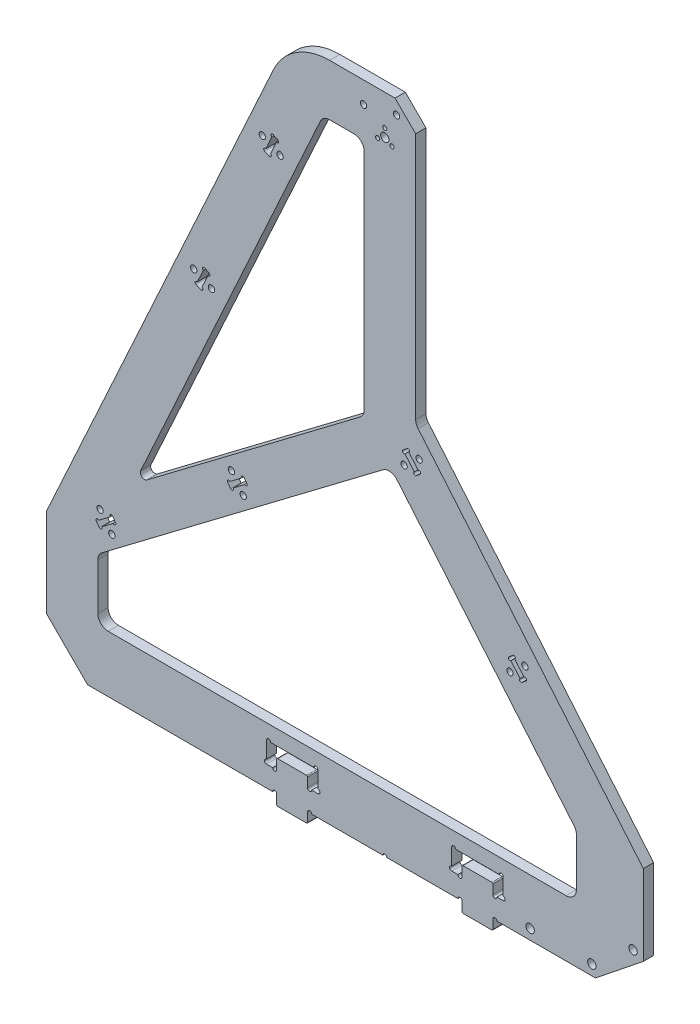
from build123d import *

# Parameters (mm, degrees)
SKETCH_1_R          = 2
SKETCH_1_R_2        = 1
SKETCH_1_R_3        = 2.05
EXTRUDE_1_DEPTH     = 2.5
EXTRUDE_2_DEPTH     = 5
CHAMFER_1_SIZE      = 10
FILLET_1_R          = 5
FILLET_2_R          = 2
CHAMFER_2_SIZE      = 20
FILLET_3_R          = 30
CUT_EXTRUDE_1_DEPTH = 6
SKETCH_4_R          = 1.55
CUT_EXTRUDE_2_DEPTH = 6
SKETCH_5_R          = 0.75
CUT_EXTRUDE_3_DEPTH = 6
SKETCH_6_R          = 1.55
CUT_EXTRUDE_4_DEPTH = 6
SKETCH_7_R          = 1
CUT_EXTRUDE_5_DEPTH = 6
SKETCH_8_W          = 15
SKETCH_8_H          = 5
EXTRUDE_3_DEPTH     = 5
CUT_EXTRUDE_7_DEPTH = 6
SKETCH_9_R          = 1
CUT_EXTRUDE_6_DEPTH = 6
FILLET_4_R          = 0.5


with BuildPart() as part:
    # 草图1 → 凸台-拉伸1 (new body, symmetric)
    with BuildSketch(Plane.XY):
        Polygon((-46.051103509, 19), (15, 19), (15, -113.030948747), (125.6, -244.838896088), (125.6, -302.5), (-164.4, -302.5), (-164.4, -239.550148641), align=None)
        Circle(SKETCH_1_R, mode=Mode.SUBTRACT)
        with Locations((0, 4)):
            Circle(SKETCH_1_R_2, mode=Mode.SUBTRACT)
        with Locations((3.464101615, -2)):
            Circle(SKETCH_1_R_2, mode=Mode.SUBTRACT)
        with Locations((-3.464101615, -2)):
            Circle(SKETCH_1_R_2, mode=Mode.SUBTRACT)
        with Locations((70.6, -297.5)):
            Circle(SKETCH_1_R_3, mode=Mode.SUBTRACT)
        with Locations((100.6, -297.5)):
            Circle(SKETCH_1_R_3, mode=Mode.SUBTRACT)
        with Locations((120.6, -281.5)):
            Circle(SKETCH_1_R_3, mode=Mode.SUBTRACT)
        Polygon((93.1, -245), (93.1, -275), (-139.4, -275), (-139.4, -245), (-30, -6), (-10, -6), (-10, -122.130204604), align=None, mode=Mode.SUBTRACT)
    extrude(amount=EXTRUDE_1_DEPTH, both=True)

    # 草图2 → 凸台-拉伸2 (add)
    with BuildSketch(Plane.XY.offset(2.5)):
        Polygon((-139.4, -245), (2.872444028, -137.470986019), (-10, -122.130204604), (-121.854574134, -206.669499251), align=None)
    extrude(amount=-EXTRUDE_2_DEPTH)

    # 倒角1
    chamfer_1_edges = [part.edges().sort_by_distance(p)[0] for p in [
        (15, 19, 0),
    ]]
    chamfer(chamfer_1_edges, length=CHAMFER_1_SIZE)

    # 圆角1
    fillet_1_edges = [part.edges().sort_by_distance(p)[0] for p in [
        (15, -113.030948747, 0),
        (93.1, -245, 0),
        (-10, -122.130204604, 0),
        (-10, -6, 0),
        (-30, -6, 0),
        (-139.4, -245, 0),
        (-139.4, -275, 0),
        (93.1, -275, 0),
        (2.872444028, -137.470986019, 0),
    ]]
    fillet(fillet_1_edges, radius=FILLET_1_R)

    # 圆角2
    fillet_2_edges = [part.edges().sort_by_distance(p)[0] for p in [
        (-121.854574134, -206.669499251, 0),
    ]]
    fillet(fillet_2_edges, radius=FILLET_2_R)

    # 倒角2
    chamfer_2_edges = [part.edges().sort_by_distance(p)[0] for p in [
        (-164.4, -302.5, 0),
    ]]
    chamfer(chamfer_2_edges, length=CHAMFER_2_SIZE)

    # 圆角3
    fillet_3_edges = [part.edges().sort_by_distance(p)[0] for p in [
        (-46.051103509, 19, 0),
    ]]
    fillet(fillet_3_edges, radius=FILLET_3_R)

    # 草图3 → 切除-拉伸1 (cut, through all)
    with BuildSketch(Plane.XY.offset(2.5)):
        Polygon((125.6, -283.903124237), (102.353905297, -302.5), (125.6, -302.5), align=None)
    extrude(amount=-CUT_EXTRUDE_1_DEPTH, mode=Mode.SUBTRACT)

    # 草图4 → 切除-拉伸2 (cut, through all)
    with BuildSketch(Plane.XY.offset(2.5)):
        with Locations((-84.165975689, -105.712906131)):
            Circle(SKETCH_4_R)
        with Locations((-92.804029823, -101.758918171)):
            Circle(SKETCH_4_R)
        with Locations((-50.86923498, -32.971397635)):
            Circle(SKETCH_4_R)
        with Locations((-59.507289114, -29.017409676)):
            Circle(SKETCH_4_R)
        with Locations((-74.508632231, -177.466406471)):
            Circle(SKETCH_4_R)
        with Locations((-68.780555523, -185.045267679)):
            Circle(SKETCH_4_R)
        with Locations((-132.60254465, -233.281703119)):
            Circle(SKETCH_4_R)
        with Locations((-138.330621358, -225.70284191)):
            Circle(SKETCH_4_R)
        with Locations((68.083818222, -188.35063948)):
            Circle(SKETCH_4_R)
        with Locations((60.806396012, -194.457121772)):
            Circle(SKETCH_4_R)
        with Locations((16.660809447, -127.06708403)):
            Circle(SKETCH_4_R)
        with Locations((9.383387237, -133.173566322)):
            Circle(SKETCH_4_R)
        Polygon((10.781785538, -125.50576956), (8.86667443, -127.112738584), (15.262411147, -134.734880793), (17.177522254, -133.127911769), align=None)
        Polygon((60.289683205, -188.396294033), (62.204794313, -186.789325009), (68.600531029, -194.411467218), (66.685419921, -196.018436242), align=None)
        Polygon((-138.681818649, -233.489194423), (-130.743958751, -227.489787765), (-132.251347359, -225.495350605), (-140.189207257, -231.494757263), align=None)
        Polygon((-76.36721813, -183.258321824), (-68.429358232, -177.258915166), (-66.921969624, -179.253352326), (-74.859829522, -185.252758984), align=None)
        Polygon((-54.254207055, -25.950529523), (-51.981034914, -26.99105267), (-56.12231704, -36.038277789), (-58.39548918, -34.997754642), align=None)
        Polygon((-85.277775623, -99.732561165), (-87.550947763, -98.692038018), (-91.692229889, -107.739263137), (-89.419057749, -108.779786284), align=None)
    extrude(amount=-CUT_EXTRUDE_2_DEPTH, mode=Mode.SUBTRACT)

    # 草图5 → 切除-拉伸3 (cut, through all)
    with BuildSketch(Plane.XY.offset(2.5)):
        with Locations((-85.589932567, -100.414512807)):
            Circle(SKETCH_5_R)
        with Locations((-87.863104708, -99.37398966)):
            Circle(SKETCH_5_R)
        with Locations((-91.380072945, -107.057311495)):
            Circle(SKETCH_5_R)
        with Locations((-89.106900804, -108.097834642)):
            Circle(SKETCH_5_R)
        with Locations((-58.083332236, -34.315803)):
            Circle(SKETCH_5_R)
        with Locations((-55.810160096, -35.356326147)):
            Circle(SKETCH_5_R)
        with Locations((-54.566363999, -26.632481165)):
            Circle(SKETCH_5_R)
        with Locations((-52.293191858, -27.673004312)):
            Circle(SKETCH_5_R)
        with Locations((-139.590876108, -231.042540681)):
            Circle(SKETCH_5_R)
        with Locations((-138.083487501, -233.036977841)):
            Circle(SKETCH_5_R)
        with Locations((-132.849678507, -225.947567187)):
            Circle(SKETCH_5_R)
        with Locations((-131.342289899, -227.942004348)):
            Circle(SKETCH_5_R)
        with Locations((-74.261498374, -184.800542402)):
            Circle(SKETCH_5_R)
        with Locations((-75.768886981, -182.806105242)):
            Circle(SKETCH_5_R)
        with Locations((-69.02768938, -177.711131748)):
            Circle(SKETCH_5_R)
        with Locations((-67.520300772, -179.705568908)):
            Circle(SKETCH_5_R)
        with Locations((9.348765137, -127.687271916)):
            Circle(SKETCH_5_R)
        with Locations((11.263876245, -126.080302892)):
            Circle(SKETCH_5_R)
        with Locations((14.780320439, -134.160347461)):
            Circle(SKETCH_5_R)
        with Locations((16.695431547, -132.553378436)):
            Circle(SKETCH_5_R)
        with Locations((60.771773912, -188.970827366)):
            Circle(SKETCH_5_R)
        with Locations((62.68688502, -187.363858341)):
            Circle(SKETCH_5_R)
        with Locations((66.203329214, -195.44390291)):
            Circle(SKETCH_5_R)
        with Locations((68.118440322, -193.836933886)):
            Circle(SKETCH_5_R)
    extrude(amount=-CUT_EXTRUDE_3_DEPTH, mode=Mode.SUBTRACT)

    # 草图6 → 切除-拉伸4 (cut, through all)
    with BuildSketch(Plane.XY.offset(2.5)):
        with Locations((-10.341599982, 8.677632731)):
            Circle(SKETCH_6_R)
        with Locations((5.705346533, 12.235155125)):
            Circle(SKETCH_6_R)
    extrude(amount=-CUT_EXTRUDE_4_DEPTH, mode=Mode.SUBTRACT)

    # 草图7 → 切除-拉伸5 (cut, through all)
    with BuildSketch(Plane.XY.offset(2.5)):
        with Locations((0, -302.5)):
            Circle(SKETCH_7_R)
    extrude(amount=-CUT_EXTRUDE_5_DEPTH, mode=Mode.SUBTRACT)

    # 草图8 → 凸台-拉伸3 (add)
    with BuildSketch(Plane.XY.offset(2.5)):
        with Locations((-45, -305)):
            Rectangle(SKETCH_8_W, SKETCH_8_H)
        with Locations((45, -305)):
            Rectangle(SKETCH_8_W, SKETCH_8_H)
    extrude(amount=-EXTRUDE_3_DEPTH)

    # 草图10 → 切除-拉伸7 (cut, through all)
    with BuildSketch(Plane.XY.offset(2.5)):
        Polygon((-57.5, -282.3), (-57.5, -292.4), (-52.5, -292.4), (-52.5, -287.4), (-37.5, -287.4), (-37.5, -292.4), (-32.5, -292.4), (-32.5, -282.3), align=None)
        Polygon((32.5, -282.3), (57.5, -282.3), (57.5, -292.4), (52.5, -292.4), (52.5, -287.4), (37.5, -287.4), (37.5, -292.4), (32.5, -292.4), align=None)
    extrude(amount=-CUT_EXTRUDE_7_DEPTH, mode=Mode.SUBTRACT)

    # 草图9 → 切除-拉伸6 (cut, through all)
    with BuildSketch(Plane.XY.offset(2.5)):
        with Locations((-53.5, -302.5)):
            Circle(SKETCH_9_R)
        with Locations((-36.5, -302.5)):
            Circle(SKETCH_9_R)
        with Locations((36.5, -302.5)):
            Circle(SKETCH_9_R)
        with Locations((53.5, -302.5)):
            Circle(SKETCH_9_R)
        with Locations((-53.5, -292.4)):
            Circle(SKETCH_9_R)
        with Locations((-57.5, -291.4)):
            Circle(SKETCH_9_R)
        with Locations((-32.5, -291.4)):
            Circle(SKETCH_9_R)
        with Locations((-36.5, -292.4)):
            Circle(SKETCH_9_R)
        with Locations((-33.5, -282.3)):
            Circle(SKETCH_9_R)
        with Locations((-56.5, -282.3)):
            Circle(SKETCH_9_R)
        with Locations((56.5, -282.3)):
            Circle(SKETCH_9_R)
        with Locations((57.5, -291.4)):
            Circle(SKETCH_9_R)
        with Locations((53.5, -292.4)):
            Circle(SKETCH_9_R)
        with Locations((36.5, -292.4)):
            Circle(SKETCH_9_R)
        with Locations((32.5, -291.4)):
            Circle(SKETCH_9_R)
        with Locations((33.5, -282.3)):
            Circle(SKETCH_9_R)
    extrude(amount=-CUT_EXTRUDE_6_DEPTH, mode=Mode.SUBTRACT)

    # 圆角4
    fillet_4_edges = [part.edges().sort_by_distance(p)[0] for p in [
        (-52.5, -307.5, 0),
        (-37.5, -307.5, 0),
        (37.5, -307.5, 0),
        (52.5, -307.5, 0),
        (-37.5, -287.4, 0),
        (-52.5, -287.4, 0),
        (52.5, -287.4, 0),
        (37.5, -287.4, 0),
    ]]
    fillet(fillet_4_edges, radius=FILLET_4_R)


solid = part.part
